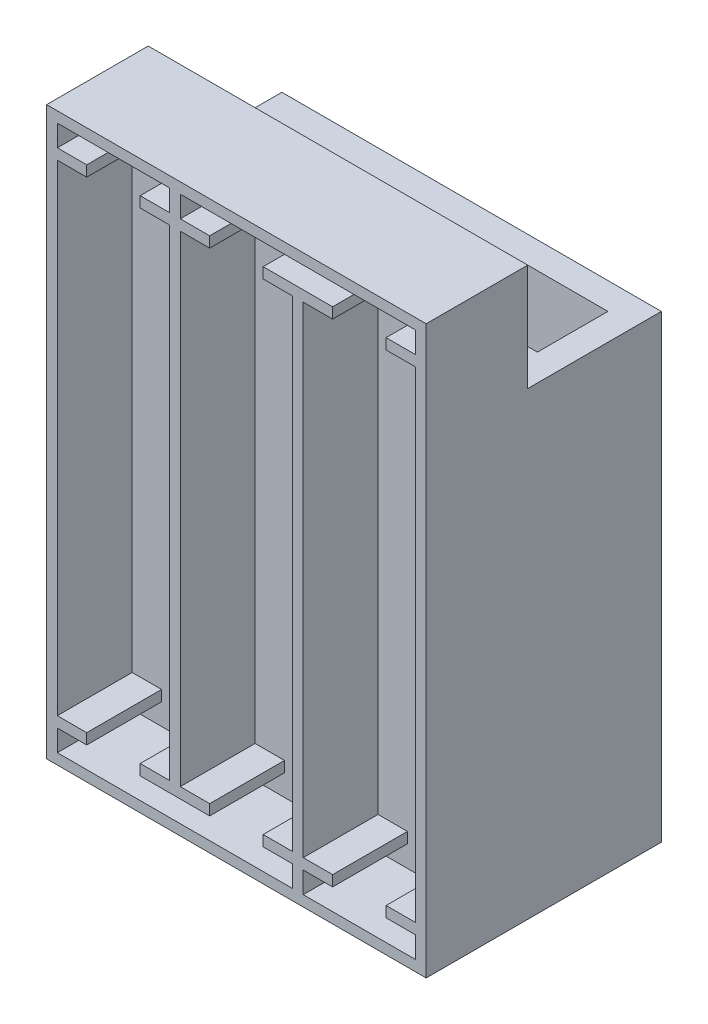
from build123d import *

# Parameters (mm, degrees)
SKETCH1_W           = 30.5
SKETCH1_H           = 10
BOSS_EXTRUDE1_DEPTH = 2.5
SKETCH2_W           = 35.5
SKETCH2_H           = 15
BOSS_EXTRUDE3_DEPTH = 43
SKETCH3_W           = 7
SKETCH3_H           = 3.4
CUT_EXTRUDE1_DEPTH  = 29
SKETCH4_W           = 35.5
SKETCH4_H           = 2.5
BOSS_EXTRUDE4_DEPTH = 10
SKETCH5_W           = 35.5
SKETCH5_H           = 53
SKETCH5_W_2         = 33.5
SKETCH5_H_2         = 51
BOSS_EXTRUDE5_DEPTH = 7
SKETCH6_W           = 10.5
SKETCH6_H           = 45
BOSS_EXTRUDE6_DEPTH = 7
SKETCH7_W           = 5
SKETCH7_H           = 1
SKETCH7_W_2         = 1
SKETCH7_H_2         = 2
CUT_EXTRUDE2_DEPTH  = 7
SKETCH8_W           = 1.6
SKETCH8_H           = 44
CUT_EXTRUDE3_DEPTH  = 2.5


with BuildPart() as part:
    # Sketch1 → Boss-Extrude1 (new body)
    with BuildSketch(Plane(origin=(0, 0, 0), x_dir=(1, 0, 0), z_dir=(0, 1, 0))):
        Rectangle(SKETCH1_W, SKETCH1_H)
    extrude(amount=BOSS_EXTRUDE1_DEPTH)

    # Sketch2 → Boss-Extrude3 (add)
    with BuildSketch(Plane(origin=(0, 0, 0), x_dir=(1, 0, 0), z_dir=(0, 1, 0))):
        Rectangle(SKETCH2_W, SKETCH2_H)
        Polygon((-15.25, 5), (-15.25, -5), (-10.25, -5), (-10.25, -1.6), (15.25, -1.6), (15.25, 5), align=None, mode=Mode.SUBTRACT)
    extrude(amount=BOSS_EXTRUDE3_DEPTH)

    # Sketch3 → Cut-Extrude1 (cut)
    with BuildSketch(Plane(origin=(0, 43, 0), x_dir=(1, 0, 0), z_dir=(0, 1, 0))):
        with Locations((-6.75, -3.3)):
            Rectangle(SKETCH3_W, SKETCH3_H)
    extrude(amount=-CUT_EXTRUDE1_DEPTH, mode=Mode.SUBTRACT)

    # Sketch4 → Boss-Extrude4 (add)
    with BuildSketch(Plane(origin=(0, 43, 0), x_dir=(1, 0, 0), z_dir=(0, 1, 0))):
        with Locations((0, -6.25)):
            Rectangle(SKETCH4_W, SKETCH4_H)
    extrude(amount=BOSS_EXTRUDE4_DEPTH)

    # Sketch5 → Boss-Extrude5 (add)
    with BuildSketch(Plane.XY.offset(7.5)):
        with Locations((0, 26.5)):
            Rectangle(SKETCH5_W, SKETCH5_H)
        with Locations((0, 26.5)):
            Rectangle(SKETCH5_W_2, SKETCH5_H_2, mode=Mode.SUBTRACT)
    extrude(amount=BOSS_EXTRUDE5_DEPTH)

    # Sketch6 → Boss-Extrude6 (add)
    with BuildSketch(Plane.XY.offset(7.5)):
        Polygon((-6.25, 52), (-6.25, 50), (-16.75, 50), (-16.75, 49), (-6.25, 49), (-6.25, 4), (-16.75, 4), (-16.75, 3), (-6.25, 3), (-6.25, 1), (-5.25, 1), (-5.25, 3), (5.25, 3), (5.25, 1), (6.25, 1), (6.25, 3), (16.75, 3), (16.75, 4), (6.25, 4), (6.25, 49), (16.75, 49), (16.75, 50), (6.25, 50), (6.25, 52), (5.25, 52), (5.25, 50), (-5.25, 50), (-5.25, 52), align=None)
        with Locations((0, 26.5)):
            Rectangle(SKETCH6_W, SKETCH6_H, mode=Mode.SUBTRACT)
    extrude(amount=BOSS_EXTRUDE6_DEPTH)

    # Sketch7 → Cut-Extrude2 (cut)
    with BuildSketch(Plane.XY.offset(14.5)):
        with Locations((0, 49.5)):
            Rectangle(SKETCH7_W, SKETCH7_H)
        with Locations((-11.5, 49.5)):
            Rectangle(SKETCH7_W, SKETCH7_H)
        with Locations((11.5, 49.5)):
            Rectangle(SKETCH7_W, SKETCH7_H)
        with Locations((11.5, 3.5)):
            Rectangle(SKETCH7_W, SKETCH7_H)
        with Locations((5.75, 51)):
            Rectangle(SKETCH7_W_2, SKETCH7_H_2)
        with Locations((0, 3.5)):
            Rectangle(SKETCH7_W, SKETCH7_H)
        with Locations((-11.5, 3.5)):
            Rectangle(SKETCH7_W, SKETCH7_H)
        with Locations((-5.75, 2)):
            Rectangle(SKETCH7_W_2, SKETCH7_H_2)
    extrude(amount=-CUT_EXTRUDE2_DEPTH, mode=Mode.SUBTRACT)

    # Sketch8 → Cut-Extrude3 (cut)
    with BuildSketch(Plane.XY.offset(7.5)):
        with Locations((11.5, 23)):
            Rectangle(SKETCH8_W, SKETCH8_H)
    extrude(amount=-CUT_EXTRUDE3_DEPTH, mode=Mode.SUBTRACT)


solid = part.part
